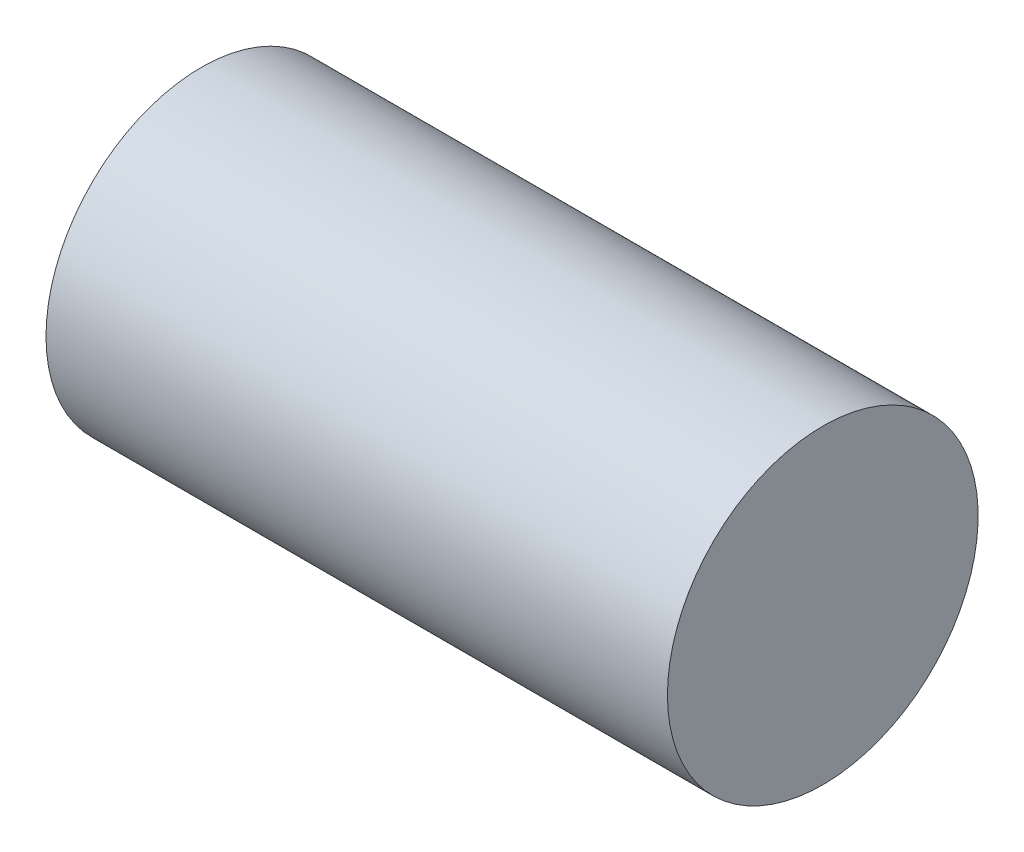
from build123d import *


with BuildPart() as part:
    # Sketch1 → Revolve1 (revolve)
    with BuildSketch(Plane.XY):
        Polygon((0, 6.35), (21.59, 6.35), (21.59, 0), (76.2, 0), (76.2, 19.05), (0, 19.05), align=None)
    revolve(axis=Axis((21.59, 0, 0), (1, 0, 0)))


solid = part.part
